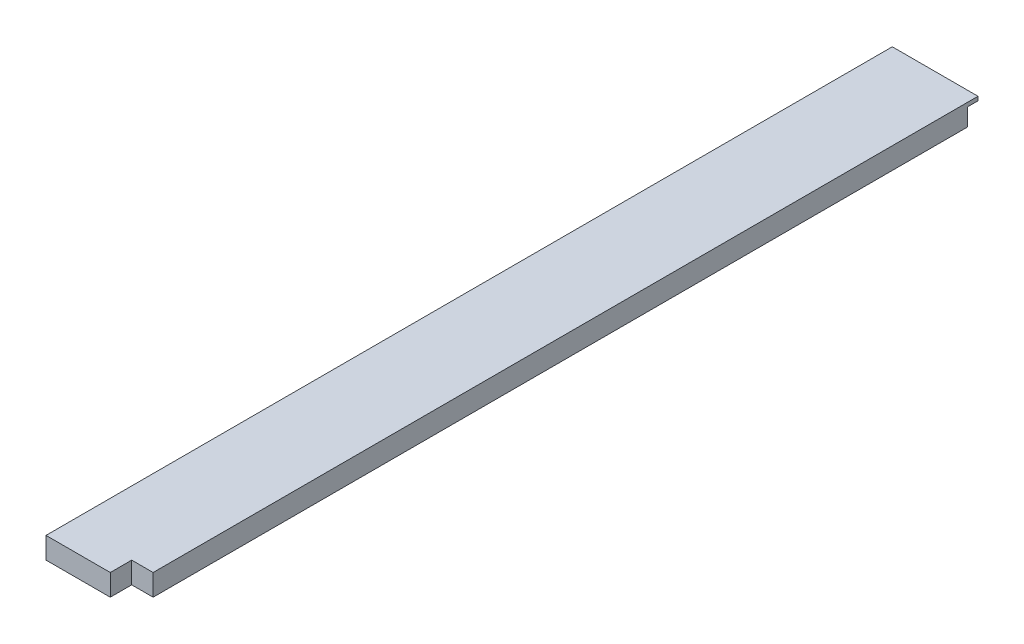
from build123d import *

# Parameters (mm, degrees)
BOSS_EXTRUDE1_DEPTH = 501.65
SKETCH3_W           = 50.8
SKETCH3_H           = 6.35
CUT_EXTRUDE1_DEPTH  = 10.3378
SKETCH4_W           = 12.7
SKETCH4_H           = 12.7
CUT_EXTRUDE4_DEPTH  = 13.7


with BuildPart() as part:
    # Sketch1 → Boss-Extrude1 (new body)
    with BuildSketch(Plane.XY):
        Polygon((0, 12.7), (38.1, 12.7), (50.8, 12.7), (50.8, 6.35), (50.8, 0), (0, 0), align=None)
    extrude(amount=BOSS_EXTRUDE1_DEPTH)

    # Sketch3 → Cut-Extrude1 (cut)
    with BuildSketch(Plane(origin=(0, 0, 0), x_dir=(1, 0, 0), z_dir=(0, 1, 0))):
        with Locations((25.4, -3.175)):
            Rectangle(SKETCH3_W, SKETCH3_H)
    extrude(amount=CUT_EXTRUDE1_DEPTH, mode=Mode.SUBTRACT)

    # Sketch4 → Cut-Extrude4 (cut, through all)
    with BuildSketch(Plane.XZ):
        with Locations((44.45, 495.3)):
            Rectangle(SKETCH4_W, SKETCH4_H)
    extrude(amount=-CUT_EXTRUDE4_DEPTH, mode=Mode.SUBTRACT)


solid = part.part
